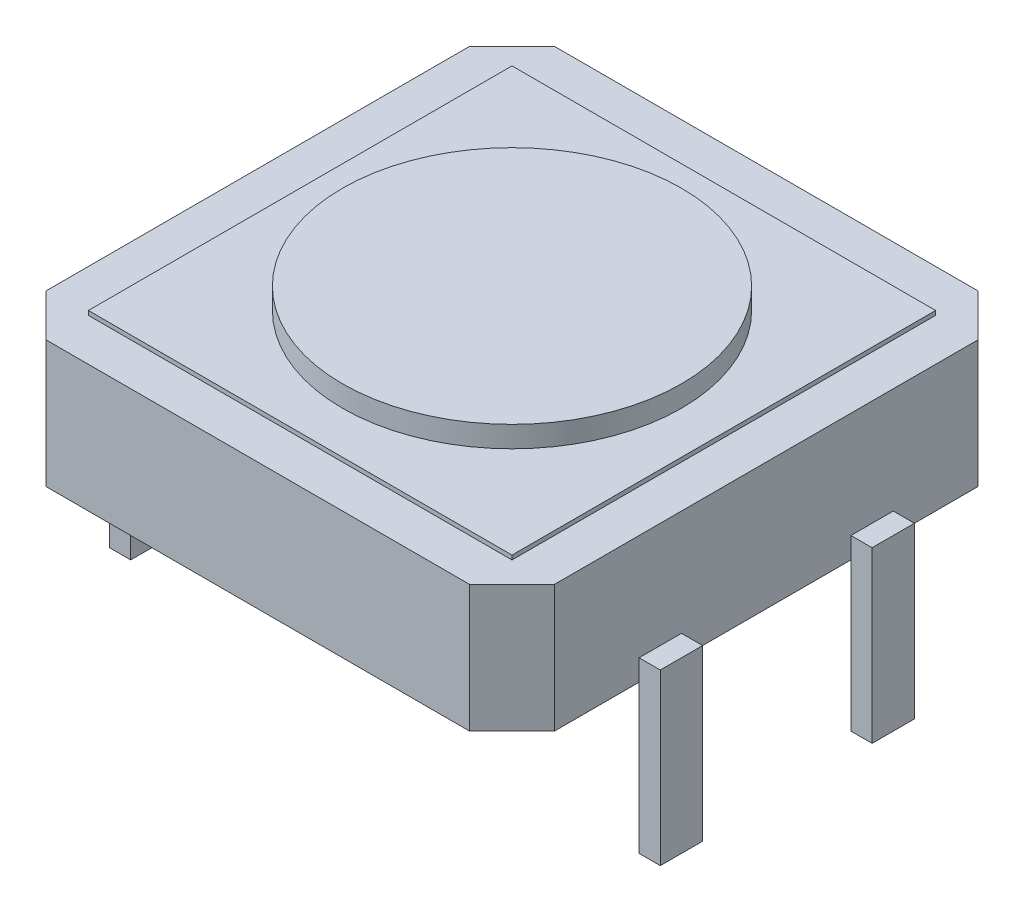
from build123d import *

# Parameters (mm, degrees)
BOSS_EXTRU_2_DEPTH         = 3
ESQUISSE2_W                = 10
ESQUISSE2_H                = 10
BOSS_EXTRU_3_DEPTH         = 0.1
ESQUISSE3_R                = 4
BOSS_EXTRU_4_DEPTH         = 0.5
ESQUISSE4_W                = 1
ESQUISSE4_H                = 4
BOSS_EXTRU_5_DEPTH         = 0.5
ESQUISSE7_W                = 1
ESQUISSE7_H                = 4
BOSS_EXTRU_7_DEPTH         = 0.5
R_P_TITION_LIN_AIRE1_COUNT = 2
R_P_TITION_LIN_AIRE1_PITCH = 5


with BuildPart() as part:
    # Esquisse1 → Boss.-Extru.2 (new body)
    with BuildSketch(Plane(origin=(0, 0, 0), x_dir=(1, 0, 0), z_dir=(0, 1, 0))):
        Polygon((0, 11), (1, 12), (11, 12), (12, 11), (12, 1), (11, 0), (1, 0), (0, 1), align=None)
    extrude(amount=BOSS_EXTRU_2_DEPTH)

    # Esquisse2 → Boss.-Extru.3 (add)
    with BuildSketch(Plane(origin=(0, 3, 0), x_dir=(1, 0, 0), z_dir=(0, 1, 0))):
        with Locations((6, 6)):
            Rectangle(ESQUISSE2_W, ESQUISSE2_H)
    extrude(amount=BOSS_EXTRU_3_DEPTH)

    # Esquisse3 → Boss.-Extru.4 (add)
    with BuildSketch(Plane(origin=(0, 3.1, 0), x_dir=(1, 0, 0), z_dir=(0, 1, 0))):
        with Locations((6, 6)):
            Circle(ESQUISSE3_R)
    extrude(amount=BOSS_EXTRU_4_DEPTH)

    # Esquisse4 → Boss.-Extru.5 (add)
    with BuildSketch(Plane.ZY):
        with Locations((-8.5, -1.5)):
            Rectangle(ESQUISSE4_W, ESQUISSE4_H)
    boss_extru_5 = extrude(amount=BOSS_EXTRU_5_DEPTH)

    # Esquisse7 → Boss.-Extru.7 (add)
    with BuildSketch(Plane(origin=(12, 0, 0), x_dir=(0, 0, -1), z_dir=(1, 0, 0))):
        with Locations((8.5, -1.5)):
            Rectangle(ESQUISSE7_W, ESQUISSE7_H)
    boss_extru_7 = extrude(amount=BOSS_EXTRU_7_DEPTH)

    # Répétition linéaire1: Boss.-Extru.5, Boss.-Extru.7 ×2
    with Locations(*[(0, 0, i * R_P_TITION_LIN_AIRE1_PITCH) for i in range(1, R_P_TITION_LIN_AIRE1_COUNT)]):
        add(boss_extru_5)
        add(boss_extru_7)


solid = part.part
